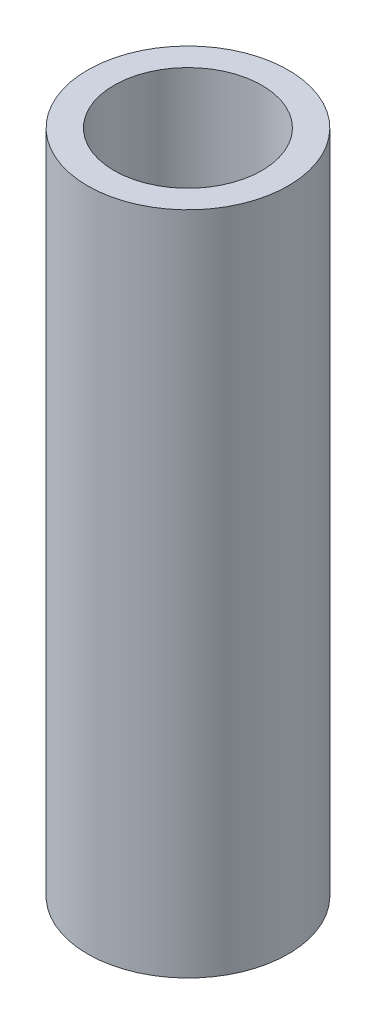
from build123d import *

# Parameters (mm, degrees)
SKETCH1_R                = 1.2065
SKETCH1_R_2              = 0.889
BOSS_EXTRUDE1_DEPTH      = 6
BOSS_EXTRUDE1_DEPTH_BACK = 2


with BuildPart() as part:
    # Sketch1 → Boss-Extrude1 (new body, two sides)
    with BuildSketch(Plane(origin=(0, 0, 0), x_dir=(1, 0, 0), z_dir=(0, 1, 0))) as boss_extrude1_sk:
        Circle(SKETCH1_R)
        Circle(SKETCH1_R_2, mode=Mode.SUBTRACT)
    extrude(amount=BOSS_EXTRUDE1_DEPTH)
    extrude(boss_extrude1_sk.sketch, amount=-BOSS_EXTRUDE1_DEPTH_BACK)


solid = part.part
